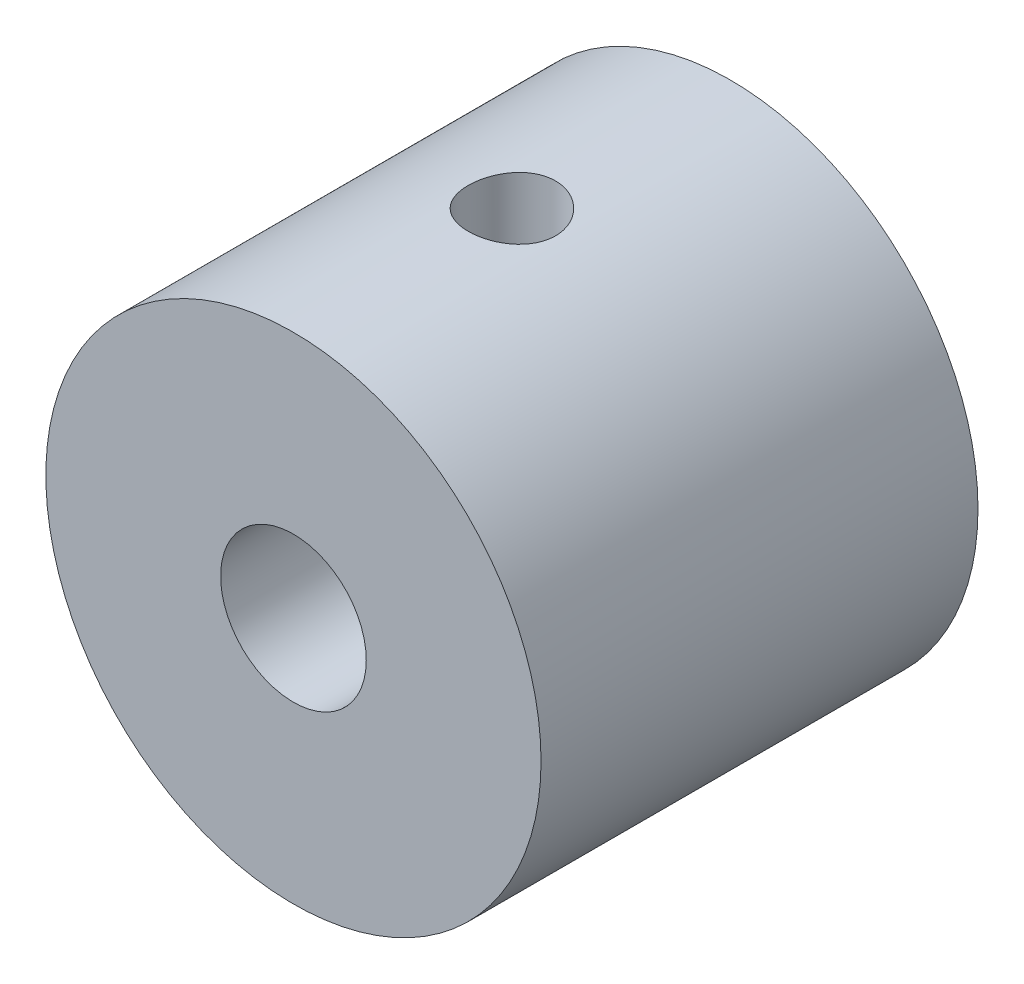
from build123d import *

# Parameters (mm, degrees)
CROQUIS1_R                 = 8.5
CROQUIS1_R_2               = 2.5
SALIENTE_EXTRUIR1_DEPTH    = 15
CROQUIS2_R                 = 1.5
CORTAR_EXTRUIR1_DEPTH      = 9.5
CORTAR_EXTRUIR1_DEPTH_BACK = 9.5


with BuildPart() as part:
    # Croquis1 → Saliente-Extruir1 (new body)
    with BuildSketch(Plane.XY):
        Circle(CROQUIS1_R)
        Circle(CROQUIS1_R_2, mode=Mode.SUBTRACT)
    extrude(amount=SALIENTE_EXTRUIR1_DEPTH)

    # Croquis2 → Cortar-Extruir1 (cut, two sides)
    with BuildSketch(Plane(origin=(0, 0, 0), x_dir=(1, 0, 0), z_dir=(0, 1, 0))) as cortar_extruir1_sk:
        with Locations((0, -7.5)):
            Circle(CROQUIS2_R)
    extrude(amount=CORTAR_EXTRUIR1_DEPTH, mode=Mode.SUBTRACT)
    extrude(cortar_extruir1_sk.sketch, amount=-CORTAR_EXTRUIR1_DEPTH_BACK, mode=Mode.SUBTRACT)


solid = part.part
